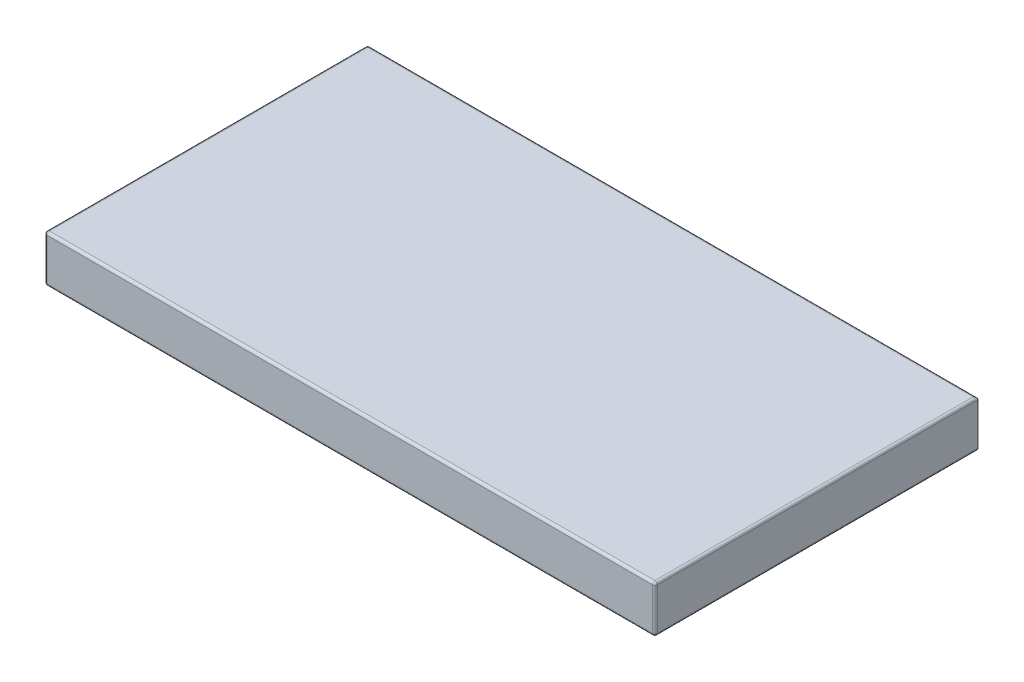
from build123d import *

# Parameters (mm, degrees)
SKETCH_1_W      = 122.3
SKETCH_1_H      = 64.75
EXTRUDE_1_DEPTH = 9.4
FILLET_1_R      = 0.5


with BuildPart() as part:
    # Эскиз1 → Бобышка-Вытянуть1 (new body)
    with BuildSketch(Plane(origin=(0, 0, 0), x_dir=(1, 0, 0), z_dir=(0, 1, 0))):
        with Locations((61.15, -32.375)):
            Rectangle(SKETCH_1_W, SKETCH_1_H)
    extrude(amount=EXTRUDE_1_DEPTH)

    # Скругление1
    fillet_1_edges = [part.edges().sort_by_distance(p)[0] for p in [
        (122.3, 9.4, 32.375),
        (61.15, 9.4, 0),
        (0, 9.4, 32.375),
        (61.15, 0, 0),
        (122.3, 0, 32.375),
        (61.15, 0, 64.75),
        (0, 0, 32.375),
        (61.15, 9.4, 64.75),
        (0, 4.7, 0),
        (122.3, 4.7, 64.75),
        (0, 4.7, 64.75),
    ]]
    fillet(fillet_1_edges, radius=FILLET_1_R)


solid = part.part
